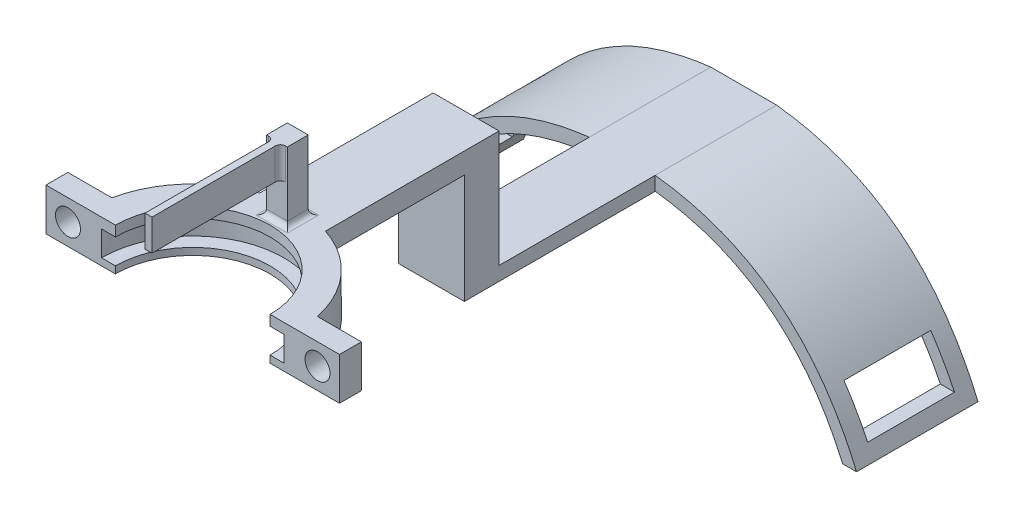
from build123d import *

# Parameters (mm, degrees)
BOSS_EXTRUDE1_DEPTH     = 8.5
BOSS_EXTRUDE2_DEPTH     = 3
BOSS_EXTRUDE3_DEPTH     = 3
SKETCH10_W              = 9.5
SKETCH10_H              = 5
BOSS_EXTRUDE4_DEPTH     = 15.78
SKETCH11_W              = 9.5
SKETCH11_H              = 2
BOSS_EXTRUDE5_DEPTH     = 40
BOSS_EXTRUDE6_DEPTH     = 6.09393
SKETCH14_R              = 1.8
CUT_EXTRUDE1_DEPTH      = 6.3
SKETCH15_W              = 51.153217575
SKETCH15_H              = 21.210560201
CUT_EXTRUDE3_DEPTH      = 19.78
SKETCH18_W              = 3
SKETCH18_H              = 3
BOSS_EXTRUDE7_DEPTH     = 8.5
FILLET1_R               = 0.75
BOSS_EXTRUDE8_DEPTH     = 1.5
FILLET2_R               = 0.75
BOSS_EXTRUDE9_DEPTH     = 17.5
SKETCH21_W              = 12.5
SKETCH21_H              = 6
CUT_EXTRUDE4_DEPTH      = 30.0000001
CUT_EXTRUDE4_DEPTH_BACK = 39.5000001


with BuildPart() as part:
    # Sketch3 → Revolve1 (revolve)
    with BuildSketch(Plane.XY):
        Polygon((-62.694264441, 11.733728816), (-64.884531744, 11.733728816), (-64.884531744, 5.639799249), (-60.884531744, 5.639799249), (-60.884531744, 6.650679103), (-62.884531744, 6.650679103), (-62.884531744, 10.250679103), (-60.884531744, 10.250679103), (-60.884531744, 11.733728816), align=None)
    revolve(axis=Axis((-49.744264441, 0, 0), (0, 1, 0)))

    # Sketch7 → Boss-Extrude1 (add)
    with BuildSketch(Plane(origin=(0, 11.733728816, 0), x_dir=(1, 0, 0), z_dir=(0, 1, 0))):
        with BuildLine():
            Line((-50.244264441, 15.132008921), (-50.244264441, 13.130751112))
            ThreePointArc((-50.244264441, 13.130751112), (-49.744264441, 13.140267302), (-49.244264441, 13.130751112))
            Line((-49.244264441, 13.130751112), (-49.244264441, 15.132008921))
            ThreePointArc((-49.244264441, 15.132008921), (-49.744264441, 15.140267302), (-50.244264441, 15.132008921))
        make_face()
    extrude(amount=BOSS_EXTRUDE1_DEPTH)

    # Sketch8 → Boss-Extrude2 (add)
    with BuildSketch(Plane(origin=(0, 20.233728816, 0), x_dir=(1, 0, 0), z_dir=(0, 1, 0))):
        with BuildLine():
            Line((-50.244264441, 15.132008921), (-50.244264441, 13.130751112))
            Line((-50.244264441, 13.130751112), (-50.244264441, -6.369248888))
            Line((-50.244264441, -6.369248888), (-49.244264441, -6.369248888))
            Line((-49.244264441, -6.369248888), (-49.244264441, 13.130751112))
            Line((-49.244264441, 13.130751112), (-49.244264441, 15.132008921))
            ThreePointArc((-49.244264441, 15.132008921), (-49.744264441, 15.140267302), (-50.244264441, 15.132008921))
        make_face()
    extrude(amount=-BOSS_EXTRUDE2_DEPTH)

    # Sketch9 → Boss-Extrude3 (add)
    with BuildSketch(Plane(origin=(0, 11.733728816, 0), x_dir=(1, 0, 0), z_dir=(0, 1, 0))):
        with BuildLine():
            Line((-54.494264441, 14.375854548), (-54.494264441, 39.375854548))
            Line((-54.494264441, 39.375854548), (-44.994264441, 39.375854548))
            Line((-44.994264441, 39.375854548), (-44.994264441, 14.375854548))
            ThreePointArc((-44.994264441, 14.375854548), (-47.092177082, 14.906177465), (-49.244264441, 15.132008921))
            ThreePointArc((-49.244264441, 15.132008921), (-49.744264441, 15.140267302), (-50.244264441, 15.132008921))
            ThreePointArc((-50.244264441, 15.132008921), (-52.3963518, 14.906177465), (-54.494264441, 14.375854548))
        make_face()
    extrude(amount=-BOSS_EXTRUDE3_DEPTH)

    # Sketch10 → Boss-Extrude4 (add)
    with BuildSketch(Plane.XZ.offset(-8.733728816)):
        with Locations((-49.744264441, -36.875854548)):
            Rectangle(SKETCH10_W, SKETCH10_H)
    extrude(amount=BOSS_EXTRUDE4_DEPTH)

    # Sketch11 → Boss-Extrude5 (add)
    with BuildSketch(Plane(origin=(0, 0, -39.375854548), x_dir=(-1, 0, 0), z_dir=(0, 0, -1))):
        with Locations((49.744264441, -6.046271184)):
            Rectangle(SKETCH11_W, SKETCH11_H)
    extrude(amount=BOSS_EXTRUDE5_DEPTH)

    # Sketch13 → Boss-Extrude6 (add)
    with BuildSketch(Plane(origin=(0, 11.733728816, 0), x_dir=(1, 0, 0), z_dir=(0, 1, 0))):
        with BuildLine():
            Line((-28.603997139, 3.15), (-34.935307895, 3.15))
            ThreePointArc((-34.935307895, 3.15), (-34.603997139, 0), (-34.935307895, -3.15))
            Line((-34.935307895, -3.15), (-28.603997139, -3.15))
            Line((-28.603997139, -3.15), (-28.603997139, 3.15))
        make_face()
        with BuildLine():
            Line((-70.884531744, 3.15), (-70.884531744, -3.15))
            Line((-70.884531744, -3.15), (-64.553220987, -3.15))
            ThreePointArc((-64.553220987, -3.15), (-64.884531744, 0), (-64.553220987, 3.15))
            Line((-64.553220987, 3.15), (-70.884531744, 3.15))
        make_face()
    extrude(amount=-BOSS_EXTRUDE6_DEPTH)

    # Sketch14 → Cut-Extrude1 (cut)
    with BuildSketch(Plane.XY.offset(3.15)):
        with Locations((-31.769652517, 8.686764033)):
            Circle(SKETCH14_R)
        with Locations((-67.718876365, 8.686764033)):
            Circle(SKETCH14_R)
    extrude(amount=-CUT_EXTRUDE1_DEPTH, mode=Mode.SUBTRACT)

    # Sketch15 → Cut-Extrude3 (cut, through all)
    with BuildSketch(Plane(origin=(0, 11.733728816, 0), x_dir=(1, 0, 0), z_dir=(0, 1, 0))):
        with Locations((-49.018725857, -10.6052801)):
            Rectangle(SKETCH15_W, SKETCH15_H)
    extrude(amount=-CUT_EXTRUDE3_DEPTH, mode=Mode.SUBTRACT)

    # Sketch18 → Boss-Extrude7 (add)
    with BuildSketch(Plane(origin=(0, 11.733728816, 0), x_dir=(1, 0, 0), z_dir=(0, 1, 0))):
        with Locations((-49.744264441, 13.632008921)):
            Rectangle(SKETCH18_W, SKETCH18_H)
    extrude(amount=BOSS_EXTRUDE7_DEPTH)

    # Fillet1
    fillet1_edges = [part.edges().sort_by_distance(p)[0] for p in [
        (-50.744264441, 11.733728816, -15.132008921),
        (-48.744264441, 11.733728816, -15.132008921),
        (-49.744264441, 11.733728816, -12.132008921),
        (-48.244264441, 11.733728816, -13.632008921),
        (-51.244264441, 11.733728816, -13.632008921),
        (-49.744264441, 11.733728816, -15.140267302),
    ]]
    fillet(fillet1_edges, radius=FILLET1_R)

    # Sketch19 → Boss-Extrude8 (add)
    with BuildSketch(Plane(origin=(0, 20.233728816, 0), x_dir=(1, 0, 0), z_dir=(0, 1, 0))):
        with BuildLine():
            Line((-50.244264441, 15.132008921), (-51.244264441, 15.132008921))
            Line((-51.244264441, 15.132008921), (-51.244264441, 12.132008921))
            Line((-51.244264441, 12.132008921), (-50.244264441, 12.132008921))
            Line((-50.244264441, 12.132008921), (-50.244264441, -6.369248888))
            Line((-50.244264441, -6.369248888), (-49.244264441, -6.369248888))
            Line((-49.244264441, -6.369248888), (-49.244264441, 12.132008921))
            Line((-49.244264441, 12.132008921), (-48.244264441, 12.132008921))
            Line((-48.244264441, 12.132008921), (-48.244264441, 15.132008921))
            Line((-48.244264441, 15.132008921), (-49.244264441, 15.132008921))
            ThreePointArc((-49.244264441, 15.132008921), (-49.744264441, 15.140267302), (-50.244264441, 15.132008921))
        make_face()
    extrude(amount=BOSS_EXTRUDE8_DEPTH)

    # Fillet2
    fillet2_edges = [part.edges().sort_by_distance(p)[0] for p in [
        (-50.244264441, 19.483728816, -12.132008921),
        (-49.244264441, 19.483728816, -12.132008921),
    ]]
    fillet(fillet2_edges, radius=FILLET2_R)

    # Sketch20 → Boss-Extrude9 (add)
    with BuildSketch(Plane(origin=(0, 0, -79.375854548), x_dir=(-1, 0, 0), z_dir=(0, 0, -1))):
        with BuildLine():
            Line((15.994264441, -27.546271184), (17.994264441, -27.546271184))
            add(Edge.make_bspline(
                [(17.994264441, -27.546271184), (25.87775722, -9.327062953), (44.994264441, -7.046271184)],
                knots=[0, 0, 0, 0.444959485, 0.444959485, 0.444959485], degree=2))
            Line((44.994264441, -7.046271184), (54.494264441, -7.046271184))
            add(Edge.make_bspline(
                [(54.494264441, -7.046271184), (73.610771663, -9.327062953), (81.494264441, -27.546271184)],
                knots=[0.555040515, 0.555040515, 0.555040515, 1, 1, 1], degree=2))
            Line((81.494264441, -27.546271184), (83.494264441, -27.546271184))
            add(Edge.make_bspline(
                [(54.494264441, -5.046271184), (75.013161261, -7.38841158), (83.494264441, -27.546271184)],
                knots=[0.551684944, 0.551684944, 0.551684944, 1, 1, 1], degree=2))
            Line((54.494264441, -5.046271184), (44.994264441, -5.046271184))
            add(Edge.make_bspline(
                [(15.994264441, -27.546271184), (24.475367621, -7.38841158), (44.994264441, -5.046271184)],
                knots=[0, 0, 0, 0.448315056, 0.448315056, 0.448315056], degree=2))
        make_face()
    extrude(amount=-BOSS_EXTRUDE9_DEPTH)

    # Sketch21 → Cut-Extrude4 (cut, two sides)
    with BuildSketch(Plane(origin=(-44.994264441, 0, 0), x_dir=(0, 0, -1), z_dir=(1, 0, 0))) as cut_extrude4_sk:
        with Locations((70.625854548, -22.546271184)):
            Rectangle(SKETCH21_W, SKETCH21_H)
    extrude(amount=CUT_EXTRUDE4_DEPTH, mode=Mode.SUBTRACT)
    extrude(cut_extrude4_sk.sketch, amount=-CUT_EXTRUDE4_DEPTH_BACK, mode=Mode.SUBTRACT)


solid = part.part
